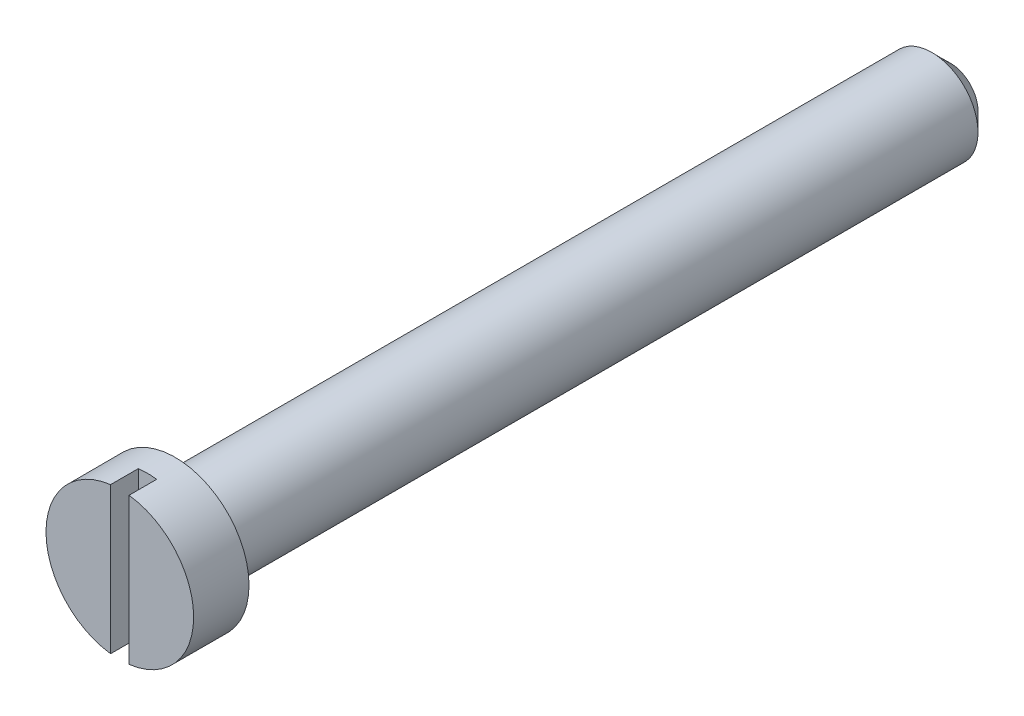
from build123d import *

# Parameters (mm, degrees)
SKETCH_1_R          = 2.5
EXTRUDE_1_DEPTH     = 45
SKETCH_2_R          = 4
EXTRUDE_2_DEPTH     = 3
CHAMFER_1_SIZE      = 1
SKETCH_3_W          = 1
SKETCH_3_H          = 8
CUT_EXTRUDE_1_DEPTH = 1.5


with BuildPart() as part:
    # Эскиз1 → Бобышка-Вытянуть1 (new body)
    with BuildSketch(Plane.XY):
        Circle(SKETCH_1_R)
    extrude(amount=EXTRUDE_1_DEPTH)

    # Эскиз2 → Бобышка-Вытянуть2 (add)
    with BuildSketch(Plane.XY.offset(45)):
        Circle(SKETCH_2_R)
    extrude(amount=-EXTRUDE_2_DEPTH)

    # Фаска1
    chamfer_1_edges = [part.edges().sort_by_distance(p)[0] for p in [
        (-2.5, 0, 0),
    ]]
    chamfer(chamfer_1_edges, length=CHAMFER_1_SIZE)

    # Эскиз3 → Вырез-Вытянуть1 (cut)
    with BuildSketch(Plane.XY.offset(45)):
        Rectangle(SKETCH_3_W, SKETCH_3_H)
    extrude(amount=-CUT_EXTRUDE_1_DEPTH, mode=Mode.SUBTRACT)


solid = part.part
